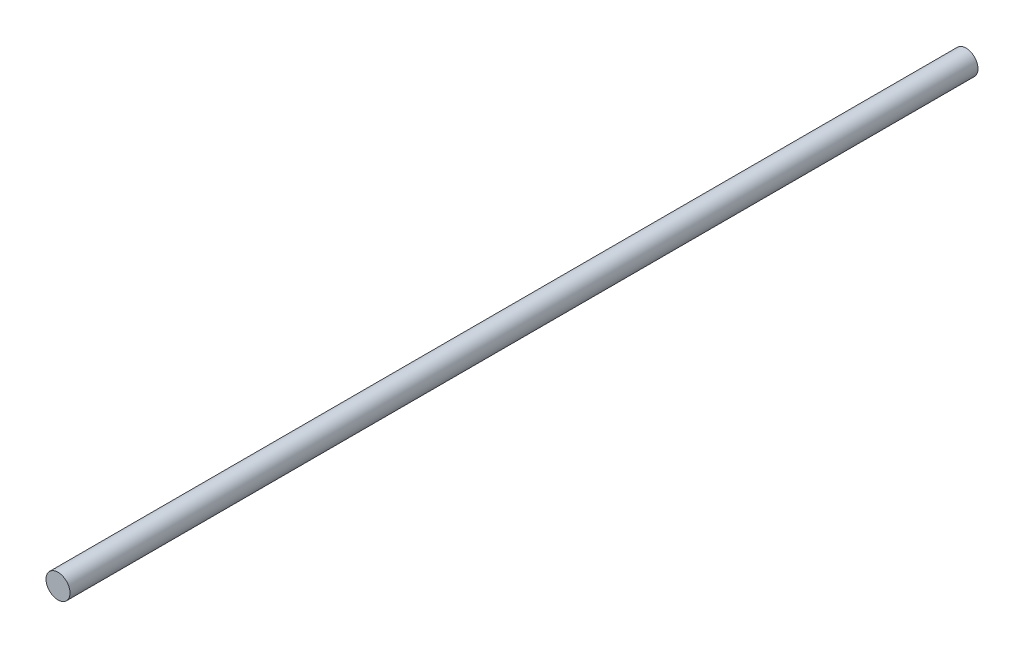
from build123d import *

# Parameters (mm, degrees)
SKETCH1_R           = 2.38125
BOSS_EXTRUDE1_DEPTH = 90


with BuildPart() as part:
    # Sketch1 → Boss-Extrude1 (new body, symmetric)
    with BuildSketch(Plane.XY):
        Circle(SKETCH1_R)
    extrude(amount=BOSS_EXTRUDE1_DEPTH, both=True)


solid = part.part
